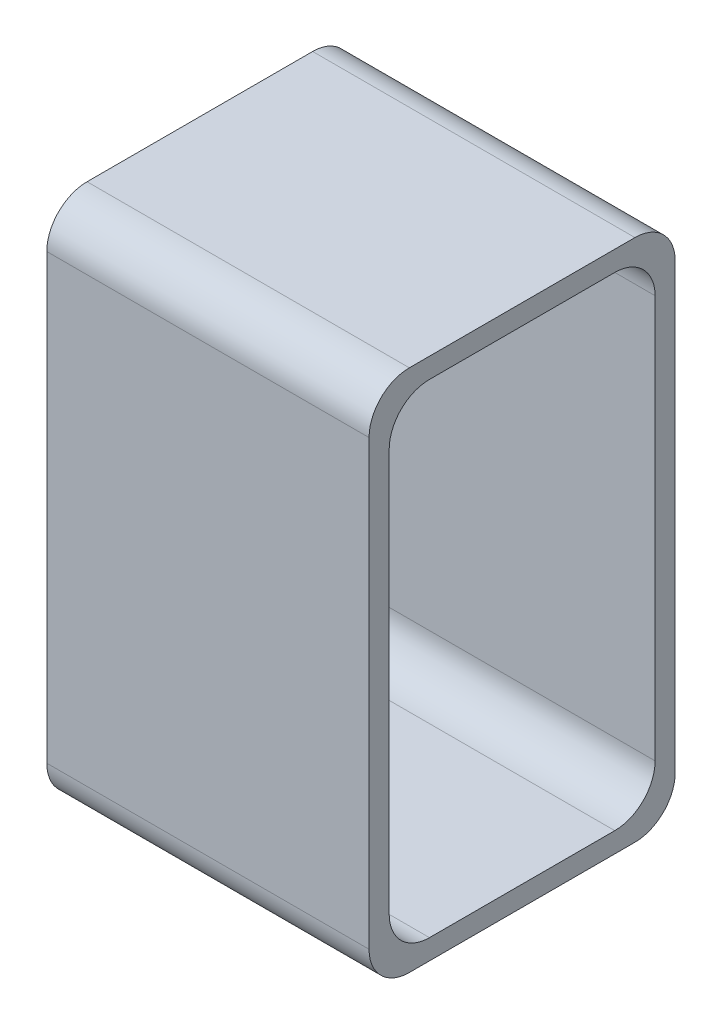
from build123d import *

# Parameters (mm, degrees)
SKETCH1_W               = 0.4
SKETCH1_H               = 0.38
BOSS_EXTRUDE1_DEPTH     = 0.65
SKETCH2_W               = 0.33
SKETCH2_H               = 0.6
CUT_EXTRUDE1_DEPTH      = 1
CUT_EXTRUDE1_DEPTH_BACK = 1.4
FILLET1_R               = 0.05


with BuildPart() as part:
    # Sketch1 → Boss-Extrude1 (new body)
    with BuildSketch(Plane(origin=(0, 0, 0), x_dir=(1, 0, 0), z_dir=(0, 1, 0))):
        with Locations((0.2, -0.19)):
            Rectangle(SKETCH1_W, SKETCH1_H)
    extrude(amount=BOSS_EXTRUDE1_DEPTH)

    # Sketch2 → Cut-Extrude1 (cut, two sides)
    with BuildSketch(Plane(origin=(0.4, 0, 0), x_dir=(0, 0, -1), z_dir=(1, 0, 0))) as cut_extrude1_sk:
        with Locations((-0.19, 0.325)):
            Rectangle(SKETCH2_W, SKETCH2_H)
    extrude(amount=CUT_EXTRUDE1_DEPTH, mode=Mode.SUBTRACT)
    extrude(cut_extrude1_sk.sketch, amount=-CUT_EXTRUDE1_DEPTH_BACK, mode=Mode.SUBTRACT)

    # Fillet1
    fillet1_edges = [part.edges().sort_by_distance(p)[0] for p in [
        (0.2, 0.65, 0),
        (0.2, 0.025, 0.355),
        (0.2, 0.625, 0.355),
        (0.2, 0.625, 0.025),
        (0.2, 0.025, 0.025),
        (0.2, 0, 0),
        (0.2, 0, 0.38),
        (0.2, 0.65, 0.38),
    ]]
    fillet(fillet1_edges, radius=FILLET1_R)


solid = part.part
